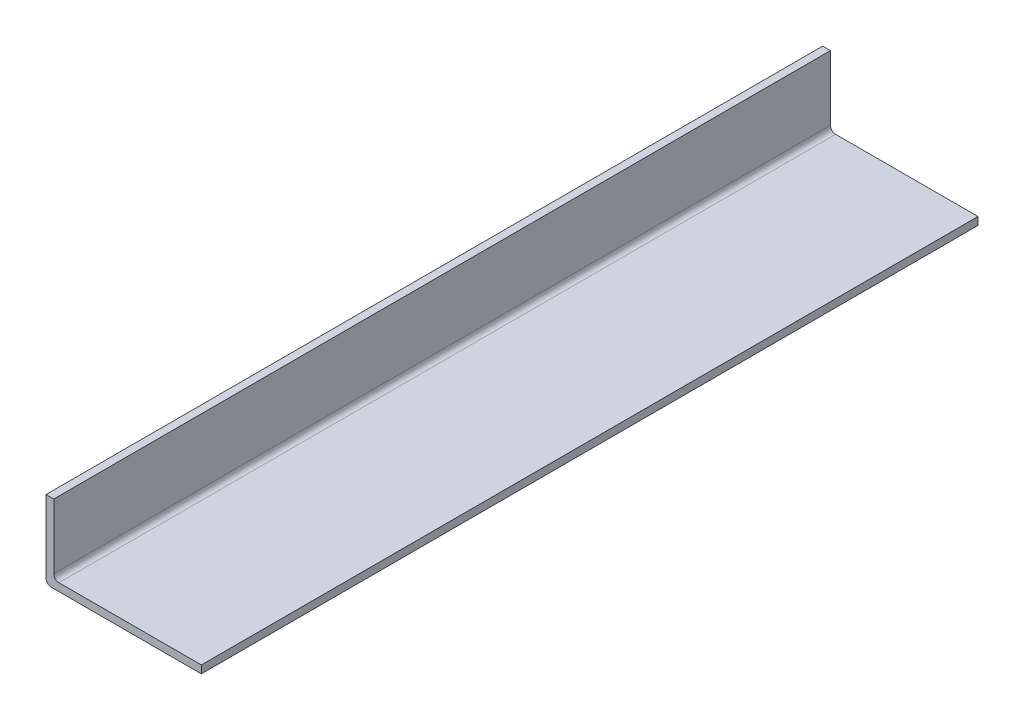
from build123d import *

# Parameters (mm, degrees)
BOSS_EXTRUDE1_DEPTH = 300
FILLET1_R           = 2


with BuildPart() as part:
    # Sketch1 → Boss-Extrude1 (new body)
    with BuildSketch(Plane.XY):
        Polygon((0, 30), (0, 0), (60, 0), (60, 3), (3, 3), (3, 30), align=None)
    extrude(amount=BOSS_EXTRUDE1_DEPTH)

    # Fillet1
    fillet1_edges = [part.edges().sort_by_distance(p)[0] for p in [
        (3, 3, 150),
        (0, 0, 150),
    ]]
    fillet(fillet1_edges, radius=FILLET1_R)


solid = part.part
